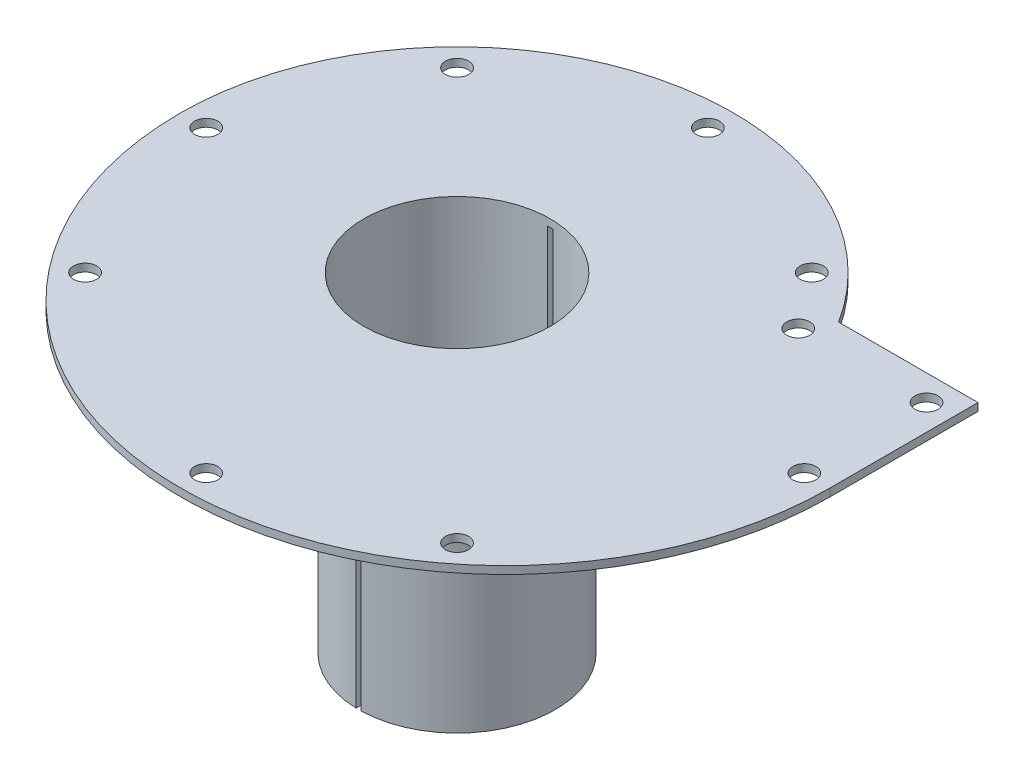
from build123d import *

# Parameters (mm, degrees)
EXTRUDE_1_DEPTH     = 1.2
SKETCH_2_R          = 15.3
SKETCH_2_R_2        = 14.5
EXTRUDE_1_2_DEPTH   = 50
EXTRUDE_2_DEPTH     = 1.2
SKETCH_8_R          = 1.8
CUT_EXTRUDE_4_DEPTH = 2.2
SKETCH_2_2_R        = 14.5
CUT_EXTRUDE_1_DEPTH = 2.2
CUT_EXTRUDE_START   = -50
SKETCH_3_W          = 0.8
SKETCH_3_H          = 35
CUT_EXTRUDE_2_DEPTH = 50


with BuildPart() as part:
    # Sketch 1 → Extrude 1 (new body)
    with BuildSketch(Plane(origin=(0, 0, 0), x_dir=(1, 0, 0), z_dir=(0, 1, 0))):
        with BuildLine():
            Line((35, 0), (35, 15))
            Line((35, 15), (50, 15))
            Line((50, 15), (50, 0))
            ThreePointArc((50, 0), (7.5, -42.5), (-35, 0))
            ThreePointArc((-35, 0), (0, 35), (35, 0))
        make_face()
    extrude(amount=EXTRUDE_1_DEPTH)

    # Sketch 2 → Extrude 1 2 (add)
    with BuildSketch(Plane(origin=(0, 0, 0), x_dir=(1, 0, 0), z_dir=(0, 1, 0))):
        Circle(SKETCH_2_R)
        Circle(SKETCH_2_R_2, mode=Mode.SUBTRACT)
    extrude(amount=-EXTRUDE_1_2_DEPTH)

    # Sketch 7 → Extrude 2 (add)
    with BuildSketch(Plane(origin=(0, 0, 0), x_dir=(1, 0, 0), z_dir=(0, 1, 0))):
        with BuildLine():
            Line((36.331804249, 23), (58, 23))
            Line((58, 23), (58, 0))
            ThreePointArc((58, 0), (7.5, -50.5), (-43, 0))
            ThreePointArc((-43, 0), (-11.973562905, 41.299319502), (36.331804249, 23))
        make_face()
        with BuildLine():
            Line((35, 0), (35, 15))
            Line((35, 15), (50, 15))
            Line((50, 15), (50, 0))
            ThreePointArc((50, 0), (7.5, -42.5), (-35, 0))
            ThreePointArc((-35, 0), (0, 35), (35, 0))
        make_face(mode=Mode.SUBTRACT)
    extrude(amount=EXTRUDE_2_DEPTH)

    # Sketch 8 → Cut-Extrude 4 (cut, through all)
    with BuildSketch(Plane(origin=(0, 0, 0), x_dir=(1, 0, 0), z_dir=(0, 1, 0))):
        with Locations((34.058772732, 19)):
            Circle(SKETCH_8_R)
        with Locations((54, 19)):
            Circle(SKETCH_8_R)
        with Locations((54, 0)):
            Circle(SKETCH_8_R)
        with Locations((7.5, -46.5)):
            Circle(SKETCH_8_R)
        with Locations((-39, 0)):
            Circle(SKETCH_8_R)
        with Locations((0, 39)):
            Circle(SKETCH_8_R)
        with Locations((36.415922611, -36.415922611)):
            Circle(SKETCH_8_R)
        with Locations((-28.915922611, -28.915922611)):
            Circle(SKETCH_8_R)
        with Locations((-27.577164466, 27.577164466)):
            Circle(SKETCH_8_R)
        with Locations((27.577164466, 27.577164466)):
            Circle(SKETCH_8_R)
    extrude(amount=CUT_EXTRUDE_4_DEPTH, mode=Mode.SUBTRACT)

    # Sketch 2_2 → Cut-Extrude 1 (cut, through all)
    with BuildSketch(Plane(origin=(0, 0, 0), x_dir=(1, 0, 0), z_dir=(0, 1, 0))):
        Circle(SKETCH_2_2_R)
    extrude(amount=CUT_EXTRUDE_1_DEPTH, mode=Mode.SUBTRACT)

    # Sketch 3 → Cut-Extrude 2 (cut)
    with BuildSketch(Plane(origin=(0, 0, 0), x_dir=(1, 0, 0), z_dir=(0, 1, 0)).offset(CUT_EXTRUDE_START)):
        Rectangle(SKETCH_3_W, SKETCH_3_H)
    extrude(amount=CUT_EXTRUDE_2_DEPTH, mode=Mode.SUBTRACT)


solid = part.part
